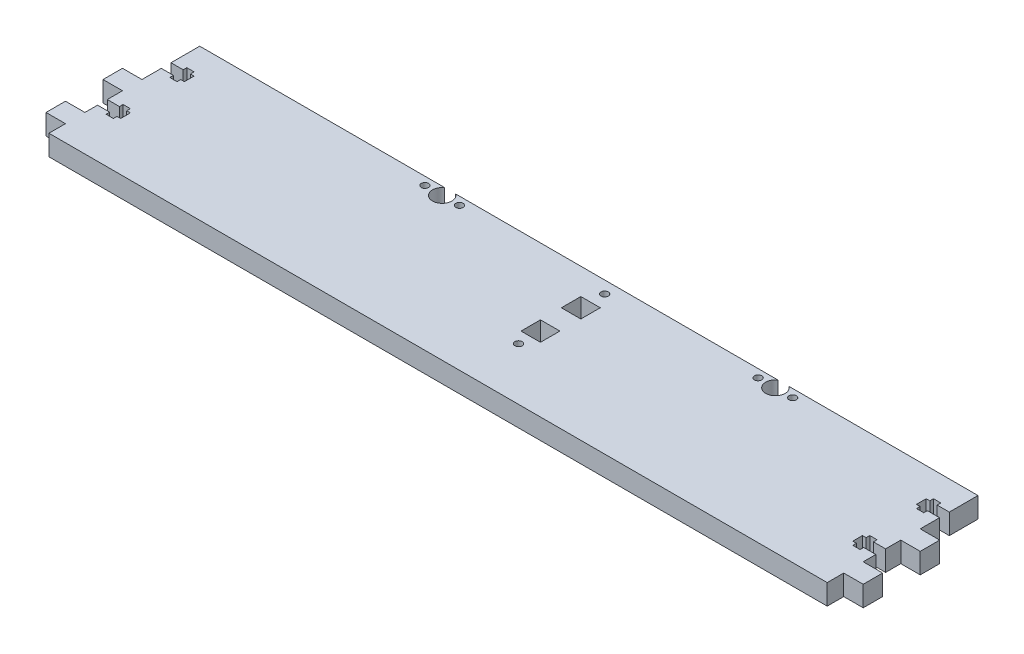
from build123d import *

# Parameters (mm, degrees)
SKETCH1_R           = 1.5
SKETCH1_W           = 8
SKETCH1_H           = 8
BOSS_EXTRUDE1_DEPTH = 8.4


with BuildPart() as part:
    # Sketch1 → Boss-Extrude1 (new body)
    with BuildSketch(Plane(origin=(0, 0, 0), x_dir=(1, 0, 0), z_dir=(0, 1, 0))):
        with BuildLine():
            Line((-160, 31), (-59.260530911, 31))
            ThreePointArc((-59.260530911, 31), (-57, 23.7), (-54.739469089, 31))
            Line((-54.739469089, 31), (77.739469089, 31))
            ThreePointArc((77.739469089, 31), (80, 23.7), (82.260530911, 31))
            Line((82.260530911, 31), (160, 31))
            Line((160, 31), (160, 19.2))
            Line((160, 19.2), (155, 19.2))
            Line((155, 19.2), (155, 20.7))
            Line((155, 20.7), (152, 20.7))
            Line((152, 20.7), (152, 19.2))
            Line((152, 19.2), (150.5, 19.2))
            Line((150.5, 19.2), (150.5, 15.2))
            Line((150.5, 15.2), (152, 15.2))
            Line((152, 15.2), (152, 13.7))
            Line((152, 13.7), (155, 13.7))
            Line((155, 13.7), (155, 15.2))
            Line((155, 15.2), (160, 15.2))
            Line((160, 15.2), (160, 7.248623706))
            Line((160, 7.248623706), (168, 7.248623706))
            Line((168, 7.248623706), (168, -0.751376294))
            Line((168, -0.751376294), (160, -0.751376294))
            Line((160, -0.751376294), (160, -7))
            Line((160, -7), (155, -7))
            Line((155, -7), (155, -5.5))
            Line((155, -5.5), (152, -5.5))
            Line((152, -5.5), (152, -7))
            Line((152, -7), (150.5, -7))
            Line((150.5, -7), (150.5, -11))
            Line((150.5, -11), (152, -11))
            Line((152, -11), (152, -12.5))
            Line((152, -12.5), (155, -12.5))
            Line((155, -12.5), (155, -11))
            Line((155, -11), (160, -11))
            Line((160, -11), (160, -16.2))
            Line((160, -16.2), (168, -16.2))
            Line((168, -16.2), (168, -24.2))
            Line((168, -24.2), (160, -24.2))
            Line((160, -24.2), (160, -31))
            Line((160, -31), (-160, -31))
            Line((-160, -31), (-160, -24.2))
            Line((-160, -24.2), (-168, -24.2))
            Line((-168, -24.2), (-168, -16.2))
            Line((-168, -16.2), (-160, -16.2))
            Line((-160, -16.2), (-160, -11))
            Line((-160, -11), (-155, -11))
            Line((-155, -11), (-155, -12.5))
            Line((-155, -12.5), (-152, -12.5))
            Line((-152, -12.5), (-152, -11))
            Line((-152, -11), (-150.5, -11))
            Line((-150.5, -11), (-150.5, -7))
            Line((-150.5, -7), (-152, -7))
            Line((-152, -7), (-152, -5.5))
            Line((-152, -5.5), (-155, -5.5))
            Line((-155, -5.5), (-155, -7))
            Line((-155, -7), (-160, -7))
            Line((-160, -7), (-160, -0.751376294))
            Line((-160, -0.751376294), (-168, -0.751376294))
            Line((-168, -0.751376294), (-168, 7.248623706))
            Line((-168, 7.248623706), (-160, 7.248623706))
            Line((-160, 7.248623706), (-160, 15.2))
            Line((-160, 15.2), (-155, 15.2))
            Line((-155, 15.2), (-155, 13.7))
            Line((-155, 13.7), (-152, 13.7))
            Line((-152, 13.7), (-152, 15.2))
            Line((-152, 15.2), (-150.5, 15.2))
            Line((-150.5, 15.2), (-150.5, 19.2))
            Line((-150.5, 19.2), (-152, 19.2))
            Line((-152, 19.2), (-152, 20.7))
            Line((-152, 20.7), (-155, 20.7))
            Line((-155, 20.7), (-155, 19.2))
            Line((-155, 19.2), (-160, 19.2))
            Line((-160, 19.2), (-160, 31))
        make_face()
        with Locations((87.1, 27.7)):
            Circle(SKETCH1_R, mode=Mode.SUBTRACT)
        with Locations((72.9, 27.7)):
            Circle(SKETCH1_R, mode=Mode.SUBTRACT)
        with Locations((-49.9, 27.7)):
            Circle(SKETCH1_R, mode=Mode.SUBTRACT)
        with Locations((-64.1, 27.7)):
            Circle(SKETCH1_R, mode=Mode.SUBTRACT)
        with Locations((11.5, 26)):
            Circle(SKETCH1_R, mode=Mode.SUBTRACT)
        with Locations((11.5, -9.4)):
            Circle(SKETCH1_R, mode=Mode.SUBTRACT)
        with Locations((11.5, -0.4)):
            Rectangle(SKETCH1_W, SKETCH1_H, mode=Mode.SUBTRACT)
        with Locations((11.5, 16.2)):
            Rectangle(SKETCH1_W, SKETCH1_H, mode=Mode.SUBTRACT)
    extrude(amount=BOSS_EXTRUDE1_DEPTH)


solid = part.part
